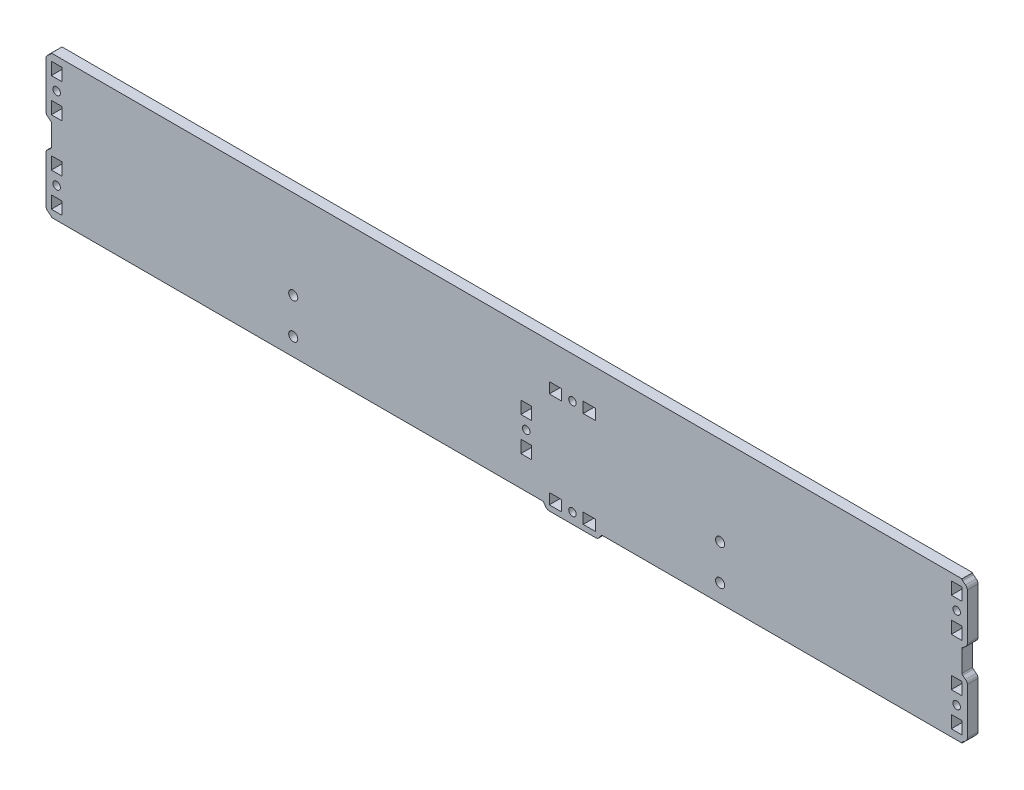
from build123d import *

# Parameters (mm, degrees)
SKETCH_1_W           = 512
SKETCH_1_H           = 80
EXTRUDE_1_DEPTH      = 6
SKETCH_2_R           = 2.55
CUT_EXTRUDE_1_DEPTH  = 7
EXTRUDE_2_DEPTH      = 6
SKETCH_3_R           = 2.1
SKETCH_3_W           = 7
SKETCH_3_H           = 6
CUT_EXTRUDE_11_DEPTH = 7
EXTRUDE_21_DEPTH     = 6
SKETCH_31_R          = 2.1
SKETCH_31_W          = 7
SKETCH_31_H          = 6
CUT_EXTRUDE_12_DEPTH = 7
EXTRUDE_22_DEPTH     = 6
SKETCH_32_R          = 2.1
SKETCH_32_W          = 7
SKETCH_32_H          = 6
CUT_EXTRUDE_13_DEPTH = 7
EXTRUDE_23_DEPTH     = 6
SKETCH_33_R          = 2.1
SKETCH_33_W          = 7
SKETCH_33_H          = 6
CUT_EXTRUDE_14_DEPTH = 7
SKETCH_35_R          = 2.1
SKETCH_35_W          = 7
SKETCH_35_H          = 6
CUT_EXTRUDE_16_DEPTH = 7
EXTRUDE_25_DEPTH     = 6
SKETCH_36_R          = 2.1
SKETCH_36_W          = 7
SKETCH_36_H          = 6
CUT_EXTRUDE_17_DEPTH = 7
SKETCH_37_R          = 2.1
SKETCH_37_W          = 7
SKETCH_37_H          = 6
CUT_EXTRUDE_18_DEPTH = 7


with BuildPart() as part:
    # Эскиз1 → Бобышка-Вытянуть1 (new body)
    with BuildSketch(Plane.XY):
        with Locations((256, -204.461538462)):
            Rectangle(SKETCH_1_W, SKETCH_1_H)
    extrude(amount=EXTRUDE_1_DEPTH)

    # Эскиз2 → Вырез-Вытянуть1 (cut, through all)
    with BuildSketch(Plane.XY.offset(6)):
        with Locations((376, -234.461538462)):
            Circle(SKETCH_2_R)
        with Locations((376, -214.461538462)):
            Circle(SKETCH_2_R)
        with Locations((136, -234.461538462)):
            Circle(SKETCH_2_R)
        with Locations((136, -214.461538462)):
            Circle(SKETCH_2_R)
    extrude(amount=-CUT_EXTRUDE_1_DEPTH, mode=Mode.SUBTRACT)

    # Эскиз21 → Бобышка-Вытянуть2 (add)
    with BuildSketch(Plane(origin=(462, -227.461538462, 0), x_dir=(0, -1, 0), z_dir=(0, 0, 1))):
        with BuildLine():
            Line((13, 53), (-13, 53))
            ThreePointArc((-13, 53), (-14.118033989, 52.736067977), (-15, 52))
            Line((-15, 52), (-16.2, 50.4))
            ThreePointArc((-16.2, 50.4), (-16.552786405, 50.105572809), (-17, 50))
            Line((-17, 50), (17, 50))
            ThreePointArc((17, 50), (16.552786405, 50.105572809), (16.2, 50.4))
            Line((16.2, 50.4), (15, 52))
            ThreePointArc((15, 52), (14.118033989, 52.736067977), (13, 53))
        make_face()
    extrude(amount=EXTRUDE_2_DEPTH)

    # Эскиз3 → Вырез-Вытянуть11 (cut, through all)
    with BuildSketch(Plane(origin=(462, -227.461538462, 6), x_dir=(0, -1, 0), z_dir=(0, 0, 1))):
        with Locations((0, 47)):
            Circle(SKETCH_3_R)
        with Locations((9.531849908, 47)):
            Rectangle(SKETCH_3_W, SKETCH_3_H)
        with Locations((-9.531849908, 47)):
            Rectangle(SKETCH_3_W, SKETCH_3_H)
    extrude(amount=-CUT_EXTRUDE_11_DEPTH, mode=Mode.SUBTRACT)

    # Эскиз22 → Бобышка-Вытянуть21 (add)
    with BuildSketch(Plane(origin=(462, -181.461538462, 0), x_dir=(0, -1, 0), z_dir=(0, 0, 1))):
        with BuildLine():
            Line((13, 53), (-13, 53))
            ThreePointArc((-13, 53), (-14.118033989, 52.736067977), (-15, 52))
            Line((-15, 52), (-16.2, 50.4))
            ThreePointArc((-16.2, 50.4), (-16.552786405, 50.105572809), (-17, 50))
            Line((-17, 50), (17, 50))
            ThreePointArc((17, 50), (16.552786405, 50.105572809), (16.2, 50.4))
            Line((16.2, 50.4), (15, 52))
            ThreePointArc((15, 52), (14.118033989, 52.736067977), (13, 53))
        make_face()
    extrude(amount=EXTRUDE_21_DEPTH)

    # Эскиз31 → Вырез-Вытянуть12 (cut, through all)
    with BuildSketch(Plane(origin=(462, -181.461538462, 6), x_dir=(0, -1, 0), z_dir=(0, 0, 1))):
        with Locations((0, 47)):
            Circle(SKETCH_31_R)
        with Locations((9.531849908, 47)):
            Rectangle(SKETCH_31_W, SKETCH_31_H)
        with Locations((-9.531849908, 47)):
            Rectangle(SKETCH_31_W, SKETCH_31_H)
    extrude(amount=-CUT_EXTRUDE_12_DEPTH, mode=Mode.SUBTRACT)

    # Эскиз23 → Бобышка-Вытянуть22 (add)
    with BuildSketch(Plane(origin=(50, -227.461538462, 0), x_dir=(0, 1, 0), z_dir=(0, 0, 1))):
        with BuildLine():
            Line((13, 53), (-13, 53))
            ThreePointArc((-13, 53), (-14.118033989, 52.736067977), (-15, 52))
            Line((-15, 52), (-16.2, 50.4))
            ThreePointArc((-16.2, 50.4), (-16.552786405, 50.105572809), (-17, 50))
            Line((-17, 50), (17, 50))
            ThreePointArc((17, 50), (16.552786405, 50.105572809), (16.2, 50.4))
            Line((16.2, 50.4), (15, 52))
            ThreePointArc((15, 52), (14.118033989, 52.736067977), (13, 53))
        make_face()
    extrude(amount=EXTRUDE_22_DEPTH)

    # Эскиз32 → Вырез-Вытянуть13 (cut, through all)
    with BuildSketch(Plane(origin=(50, -227.461538462, 6), x_dir=(0, 1, 0), z_dir=(0, 0, 1))):
        with Locations((0, 47)):
            Circle(SKETCH_32_R)
        with Locations((9.531849908, 47)):
            Rectangle(SKETCH_32_W, SKETCH_32_H)
        with Locations((-9.531849908, 47)):
            Rectangle(SKETCH_32_W, SKETCH_32_H)
    extrude(amount=-CUT_EXTRUDE_13_DEPTH, mode=Mode.SUBTRACT)

    # Эскиз24 → Бобышка-Вытянуть23 (add)
    with BuildSketch(Plane(origin=(50, -181.461538462, 0), x_dir=(0, 1, 0), z_dir=(0, 0, 1))):
        with BuildLine():
            Line((13, 53), (-13, 53))
            ThreePointArc((-13, 53), (-14.118033989, 52.736067977), (-15, 52))
            Line((-15, 52), (-16.2, 50.4))
            ThreePointArc((-16.2, 50.4), (-16.552786405, 50.105572809), (-17, 50))
            Line((-17, 50), (17, 50))
            ThreePointArc((17, 50), (16.552786405, 50.105572809), (16.2, 50.4))
            Line((16.2, 50.4), (15, 52))
            ThreePointArc((15, 52), (14.118033989, 52.736067977), (13, 53))
        make_face()
    extrude(amount=EXTRUDE_23_DEPTH)

    # Эскиз33 → Вырез-Вытянуть14 (cut, through all)
    with BuildSketch(Plane(origin=(50, -181.461538462, 6), x_dir=(0, 1, 0), z_dir=(0, 0, 1))):
        with Locations((0, 47)):
            Circle(SKETCH_33_R)
        with Locations((9.531849908, 47)):
            Rectangle(SKETCH_33_W, SKETCH_33_H)
        with Locations((-9.531849908, 47)):
            Rectangle(SKETCH_33_W, SKETCH_33_H)
    extrude(amount=-CUT_EXTRUDE_14_DEPTH, mode=Mode.SUBTRACT)

    # Эскиз35 → Вырез-Вытянуть16 (cut, through all)
    with BuildSketch(Plane(origin=(314, -214.461538462, 6), x_dir=(0, 1, 0), z_dir=(0, 0, 1))):
        with Locations((0, 47)):
            Circle(SKETCH_35_R)
        with Locations((9.531849908, 47)):
            Rectangle(SKETCH_35_W, SKETCH_35_H)
        with Locations((-9.531849908, 47)):
            Rectangle(SKETCH_35_W, SKETCH_35_H)
    extrude(amount=-CUT_EXTRUDE_16_DEPTH, mode=Mode.SUBTRACT)

    # Эскиз25 → Бобышка-Вытянуть25 (add)
    with BuildSketch(Plane(origin=(293, -194.461538462, 0), x_dir=(-1, 0, 0), z_dir=(0, 0, 1))):
        with BuildLine():
            Line((13, 53), (-13, 53))
            ThreePointArc((-13, 53), (-14.118033989, 52.736067977), (-15, 52))
            Line((-15, 52), (-16.2, 50.4))
            ThreePointArc((-16.2, 50.4), (-16.552786405, 50.105572809), (-17, 50))
            Line((-17, 50), (17, 50))
            ThreePointArc((17, 50), (16.552786405, 50.105572809), (16.2, 50.4))
            Line((16.2, 50.4), (15, 52))
            ThreePointArc((15, 52), (14.118033989, 52.736067977), (13, 53))
        make_face()
    extrude(amount=EXTRUDE_25_DEPTH)

    # Эскиз36 → Вырез-Вытянуть17 (cut, through all)
    with BuildSketch(Plane(origin=(293, -194.461538462, 6), x_dir=(-1, 0, 0), z_dir=(0, 0, 1))):
        with Locations((0, 47)):
            Circle(SKETCH_36_R)
        with Locations((9.531849908, 47)):
            Rectangle(SKETCH_36_W, SKETCH_36_H)
        with Locations((-9.531849908, 47)):
            Rectangle(SKETCH_36_W, SKETCH_36_H)
    extrude(amount=-CUT_EXTRUDE_17_DEPTH, mode=Mode.SUBTRACT)

    # Эскиз37 → Вырез-Вытянуть18 (cut, through all)
    with BuildSketch(Plane(origin=(293, -234.461538462, 6), x_dir=(1, 0, 0), z_dir=(0, 0, 1))):
        with Locations((0, 47)):
            Circle(SKETCH_37_R)
        with Locations((9.531849908, 47)):
            Rectangle(SKETCH_37_W, SKETCH_37_H)
        with Locations((-9.531849908, 47)):
            Rectangle(SKETCH_37_W, SKETCH_37_H)
    extrude(amount=-CUT_EXTRUDE_18_DEPTH, mode=Mode.SUBTRACT)


solid = part.part
